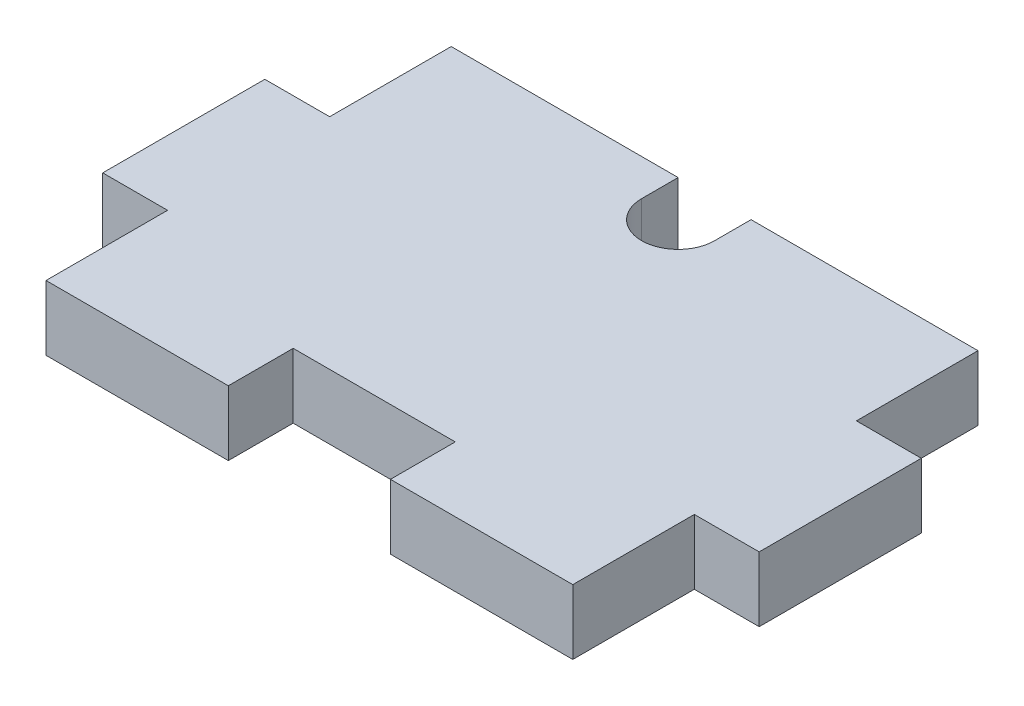
from build123d import *

# Parameters (mm, degrees)
SKETCH1_W           = 32.5
SKETCH1_H           = 25
BOSS_EXTRUDE1_DEPTH = 4
SKETCH2_R           = 2.25
SKETCH2_W           = 4.5
SKETCH2_H           = 2.25
CUT_EXTRUDE5_DEPTH  = 5
SKETCH3_W           = 4
SKETCH3_H           = 10
BOSS_EXTRUDE2_DEPTH = 4
SKETCH4_W           = 10
SKETCH4_H           = 4
CUT_EXTRUDE6_DEPTH  = 5


with BuildPart() as part:
    # Sketch1 → Boss-Extrude1 (new body)
    with BuildSketch(Plane(origin=(0, 0, 0), x_dir=(1, 0, 0), z_dir=(0, 1, 0))):
        with Locations((16.25, -12.5)):
            Rectangle(SKETCH1_W, SKETCH1_H)
    extrude(amount=BOSS_EXTRUDE1_DEPTH)

    # Sketch2 → Cut-Extrude5 (cut, through all)
    with BuildSketch(Plane(origin=(0, 4, 0), x_dir=(1, 0, 0), z_dir=(0, 1, 0))):
        with Locations((16.25, -2.25)):
            Circle(SKETCH2_R)
        with Locations((16.25, -1.125)):
            Rectangle(SKETCH2_W, SKETCH2_H)
    extrude(amount=-CUT_EXTRUDE5_DEPTH, mode=Mode.SUBTRACT)

    # Sketch3 → Boss-Extrude2 (add, through all)
    with BuildSketch(Plane(origin=(0, 4, 0), x_dir=(1, 0, 0), z_dir=(0, 1, 0))):
        with Locations((-2, -12.5)):
            Rectangle(SKETCH3_W, SKETCH3_H)
        with Locations((34.5, -12.5)):
            Rectangle(SKETCH3_W, SKETCH3_H)
    extrude(amount=-BOSS_EXTRUDE2_DEPTH)

    # Sketch4 → Cut-Extrude6 (cut, through all)
    with BuildSketch(Plane(origin=(0, 4, 0), x_dir=(1, 0, 0), z_dir=(0, 1, 0))):
        with Locations((16.25, -23)):
            Rectangle(SKETCH4_W, SKETCH4_H)
    extrude(amount=-CUT_EXTRUDE6_DEPTH, mode=Mode.SUBTRACT)


solid = part.part
